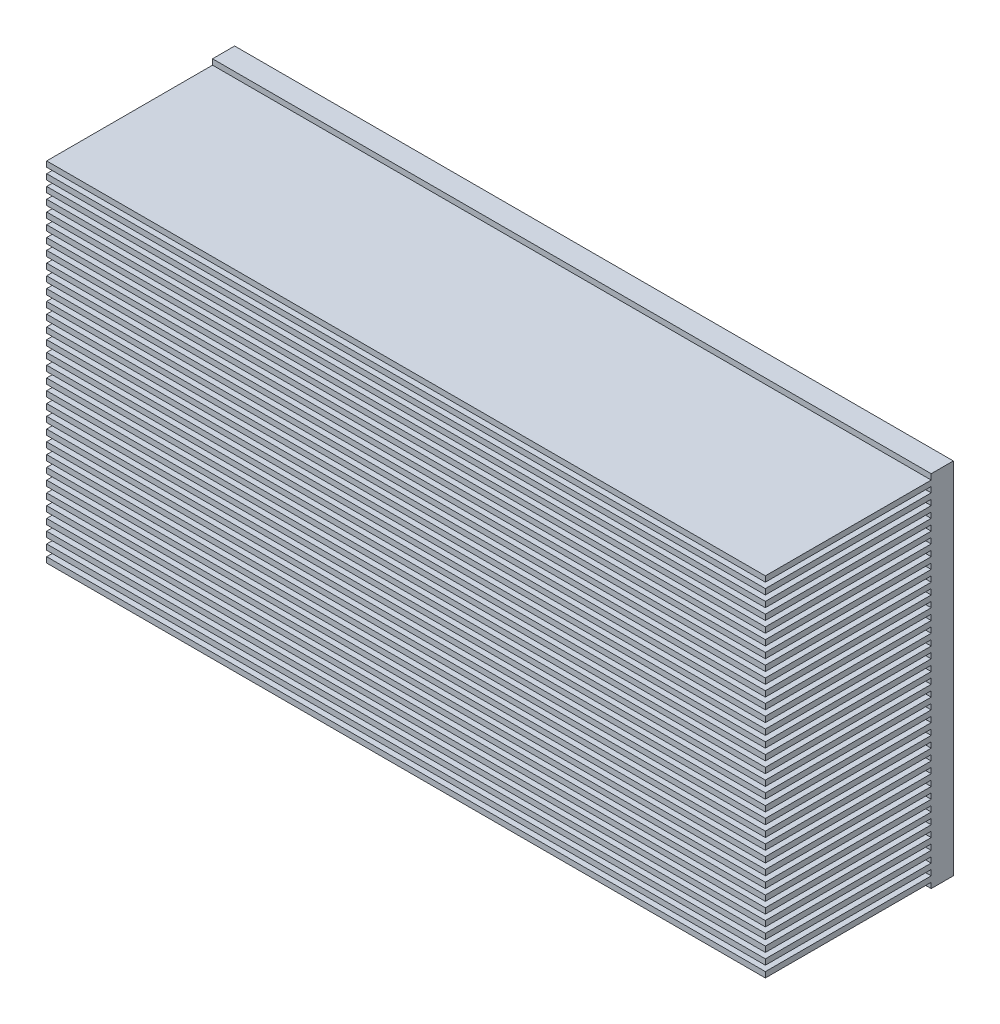
from build123d import *

# Parameters (mm, degrees)
ESQUISSE1_W             = 130
ESQUISSE1_H             = 65
BOSS_EXTRU_1_DEPTH      = 4
ESQUISSE2_W             = 130
ESQUISSE2_H             = 1
BOSS_EXTRU_2_DEPTH      = 30
ESQUISSE3_R             = 1.6
ENL_V_MAT_EXTRU_5_DEPTH = 4


with BuildPart() as part:
    # Esquisse1 → Boss.-Extru.1 (new body)
    with BuildSketch(Plane.XY):
        with Locations((65, 32.5)):
            Rectangle(ESQUISSE1_W, ESQUISSE1_H)
    extrude(amount=BOSS_EXTRU_1_DEPTH)

    # Esquisse2 → Boss.-Extru.2 (add)
    with BuildSketch(Plane.XY.offset(4)):
        with Locations((65, 1.5)):
            Rectangle(ESQUISSE2_W, ESQUISSE2_H)
        with Locations((65, 3.5)):
            Rectangle(ESQUISSE2_W, ESQUISSE2_H)
        with Locations((65, 5.5)):
            Rectangle(ESQUISSE2_W, ESQUISSE2_H)
        with Locations((65, 7.5)):
            Rectangle(ESQUISSE2_W, ESQUISSE2_H)
        with Locations((65, 9.5)):
            Rectangle(ESQUISSE2_W, ESQUISSE2_H)
        with Locations((65, 11.5)):
            Rectangle(ESQUISSE2_W, ESQUISSE2_H)
        with Locations((65, 13.5)):
            Rectangle(ESQUISSE2_W, ESQUISSE2_H)
        with Locations((65, 15.5)):
            Rectangle(ESQUISSE2_W, ESQUISSE2_H)
        with Locations((65, 17.5)):
            Rectangle(ESQUISSE2_W, ESQUISSE2_H)
        with Locations((65, 19.5)):
            Rectangle(ESQUISSE2_W, ESQUISSE2_H)
        with Locations((65, 21.5)):
            Rectangle(ESQUISSE2_W, ESQUISSE2_H)
        with Locations((65, 23.5)):
            Rectangle(ESQUISSE2_W, ESQUISSE2_H)
        with Locations((65, 25.5)):
            Rectangle(ESQUISSE2_W, ESQUISSE2_H)
        with Locations((65, 27.5)):
            Rectangle(ESQUISSE2_W, ESQUISSE2_H)
        with Locations((65, 29.5)):
            Rectangle(ESQUISSE2_W, ESQUISSE2_H)
        with Locations((65, 31.5)):
            Rectangle(ESQUISSE2_W, ESQUISSE2_H)
        with Locations((65, 33.5)):
            Rectangle(ESQUISSE2_W, ESQUISSE2_H)
        with Locations((65, 35.5)):
            Rectangle(ESQUISSE2_W, ESQUISSE2_H)
        with Locations((65, 37.5)):
            Rectangle(ESQUISSE2_W, ESQUISSE2_H)
        with Locations((65, 39.5)):
            Rectangle(ESQUISSE2_W, ESQUISSE2_H)
        with Locations((65, 41.5)):
            Rectangle(ESQUISSE2_W, ESQUISSE2_H)
        with Locations((65, 43.5)):
            Rectangle(ESQUISSE2_W, ESQUISSE2_H)
        with Locations((65, 45.5)):
            Rectangle(ESQUISSE2_W, ESQUISSE2_H)
        with Locations((65, 47.5)):
            Rectangle(ESQUISSE2_W, ESQUISSE2_H)
        with Locations((65, 49.5)):
            Rectangle(ESQUISSE2_W, ESQUISSE2_H)
        with Locations((65, 51.5)):
            Rectangle(ESQUISSE2_W, ESQUISSE2_H)
        with Locations((65, 53.5)):
            Rectangle(ESQUISSE2_W, ESQUISSE2_H)
        with Locations((65, 55.5)):
            Rectangle(ESQUISSE2_W, ESQUISSE2_H)
        with Locations((65, 57.5)):
            Rectangle(ESQUISSE2_W, ESQUISSE2_H)
        with Locations((65, 59.5)):
            Rectangle(ESQUISSE2_W, ESQUISSE2_H)
        with Locations((65, 61.5)):
            Rectangle(ESQUISSE2_W, ESQUISSE2_H)
        with Locations((65, 63.5)):
            Rectangle(ESQUISSE2_W, ESQUISSE2_H)
    extrude(amount=BOSS_EXTRU_2_DEPTH)

    # Esquisse3 → Enlèv. mat.-Extru.5 (cut)
    with BuildSketch(Plane(origin=(0, 0, 0), x_dir=(-1, 0, 0), z_dir=(0, 0, -1))):
        with Locations((-5, 55)):
            Circle(ESQUISSE3_R)
        with Locations((-29, 55)):
            Circle(ESQUISSE3_R)
        with Locations((-53, 55)):
            Circle(ESQUISSE3_R)
        with Locations((-77, 55)):
            Circle(ESQUISSE3_R)
        with Locations((-101, 55)):
            Circle(ESQUISSE3_R)
        with Locations((-125, 55)):
            Circle(ESQUISSE3_R)
        with Locations((-5, 10)):
            Circle(ESQUISSE3_R)
        with Locations((-29, 10)):
            Circle(ESQUISSE3_R)
        with Locations((-53, 10)):
            Circle(ESQUISSE3_R)
        with Locations((-77, 10)):
            Circle(ESQUISSE3_R)
        with Locations((-101, 10)):
            Circle(ESQUISSE3_R)
        with Locations((-125, 10)):
            Circle(ESQUISSE3_R)
        with Locations((-40, 32.5)):
            Circle(ESQUISSE3_R)
        with Locations((-90, 32.5)):
            Circle(ESQUISSE3_R)
    extrude(amount=-ENL_V_MAT_EXTRU_5_DEPTH, mode=Mode.SUBTRACT)


solid = part.part
